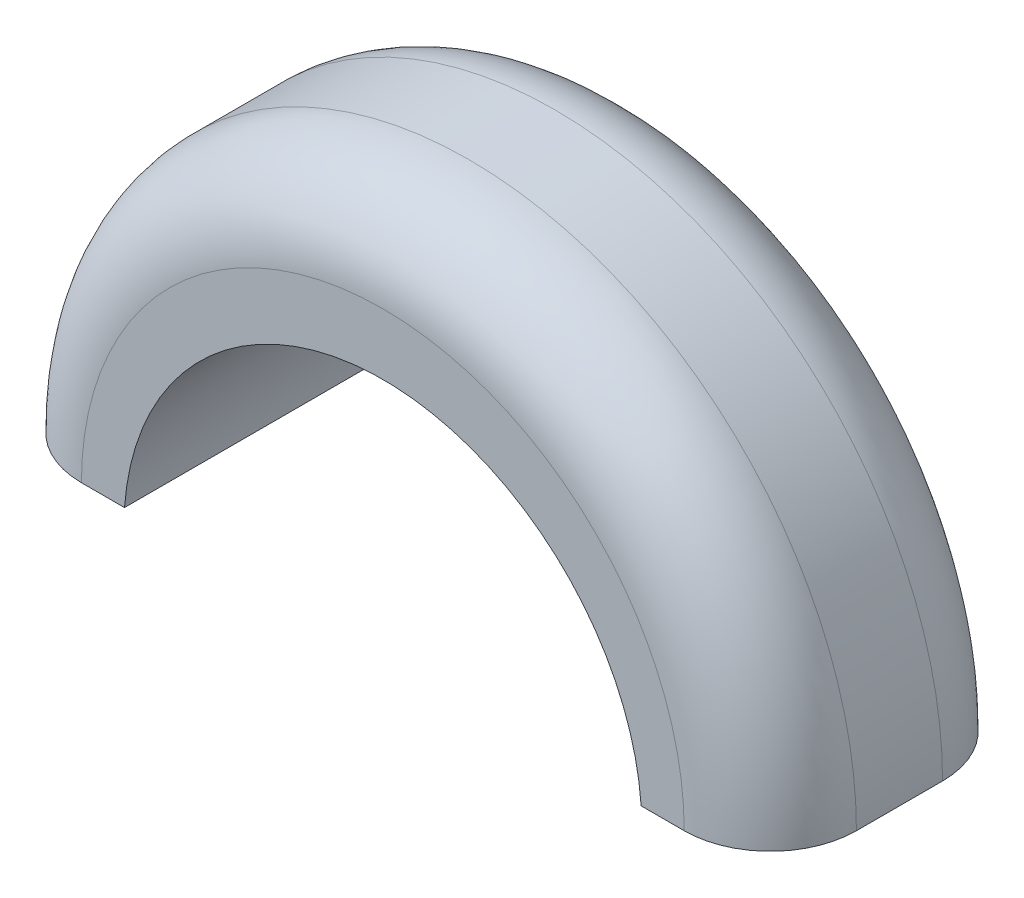
from build123d import *

# Parameters (mm, degrees)
BOSS_EXTRUDE1_DEPTH = 0.762
FILLET1_R           = 0.254


with BuildPart() as part:
    # Sketch1 → Boss-Extrude1 (new body)
    with BuildSketch(Plane.XY):
        with BuildLine():
            Line((0, 0), (0.381, 0))
            ThreePointArc((0.381, 0), (1.143, 0.708483622), (1.905, 0))
            Line((1.905, 0), (2.286, 0))
            ThreePointArc((2.286, 0), (1.143, 1.143), (0, 0))
        make_face()
    extrude(amount=BOSS_EXTRUDE1_DEPTH)

    # Fillet1
    fillet1_edges = [part.edges().sort_by_distance(p)[0] for p in [
        (1.143, 1.143, 0.762),
        (1.143, 1.143, 0),
    ]]
    fillet(fillet1_edges, radius=FILLET1_R)


solid = part.part
